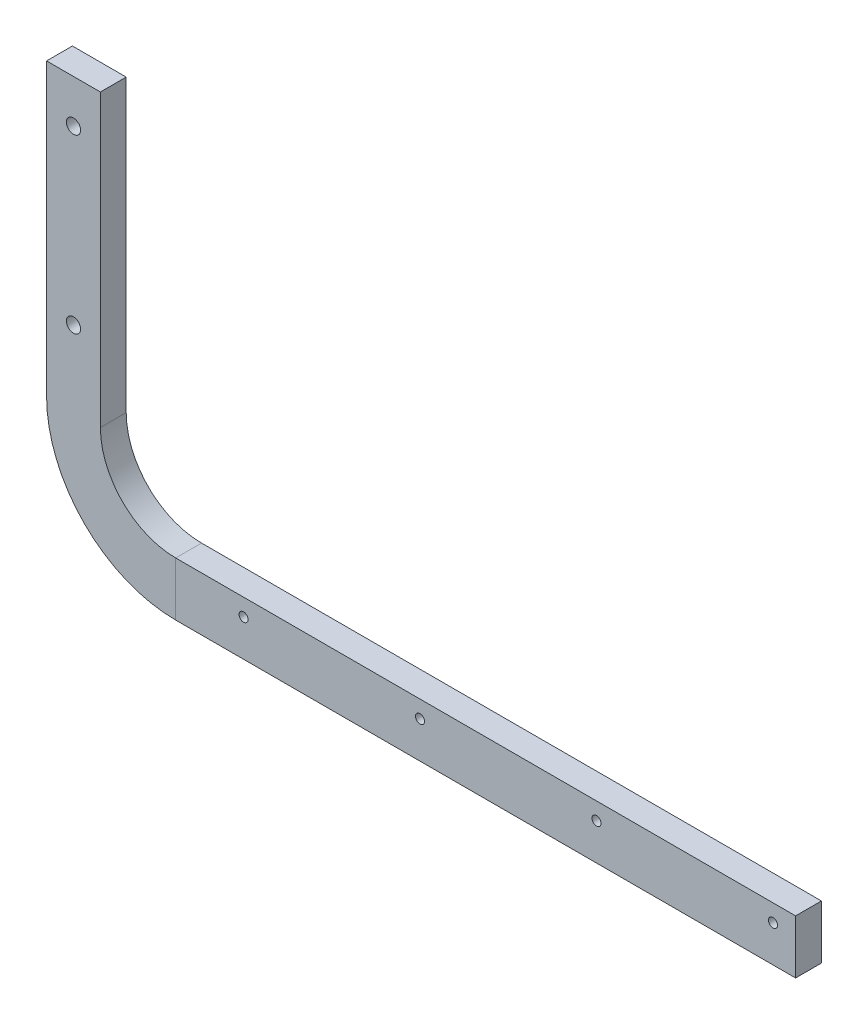
from build123d import *

# Parameters (mm, degrees)
BOSS_EXTRUDE1_DEPTH  = 6
M6_CLEARANCE_HOLE1_D = 6.6
M5_TAPPED_HOLE1_D    = 4.2
LPATTERN1_COUNT      = 4
LPATTERN1_PITCH      = 82


with BuildPart() as part:
    # Sketch1 → Boss-Extrude1 (new body, symmetric)
    with BuildSketch(Plane.XY):
        with BuildLine():
            Line((0, 0), (0, -135))
            ThreePointArc((0, -135), (17.573593129, -177.426406871), (60, -195))
            Line((60, -195), (348, -195))
            Line((348, -195), (348, -170))
            Line((348, -170), (60, -170))
            ThreePointArc((60, -170), (35.251262658, -159.748737342), (25, -135))
            Line((25, -135), (25, 0))
            Line((25, 0), (0, 0))
        make_face()
    extrude(amount=BOSS_EXTRUDE1_DEPTH, both=True)

    # M6 Clearance Hole1 (through all)
    with Locations(Plane.XY.offset(6)):
        with Locations((12.5, -20), (12.5, -100)):
            Hole(M6_CLEARANCE_HOLE1_D / 2)

    # M5 Tapped Hole1 (through all)
    with Locations(Plane.XY.offset(6)):
        with Locations((337.5, -178)):
            m5_tapped_hole1 = Hole(M5_TAPPED_HOLE1_D / 2)

    # LPattern1: M5 Tapped Hole1 ×4
    with Locations(*[(-i * LPATTERN1_PITCH, 0, 0) for i in range(1, LPATTERN1_COUNT)]):
        add(m5_tapped_hole1, mode=Mode.SUBTRACT)


solid = part.part
